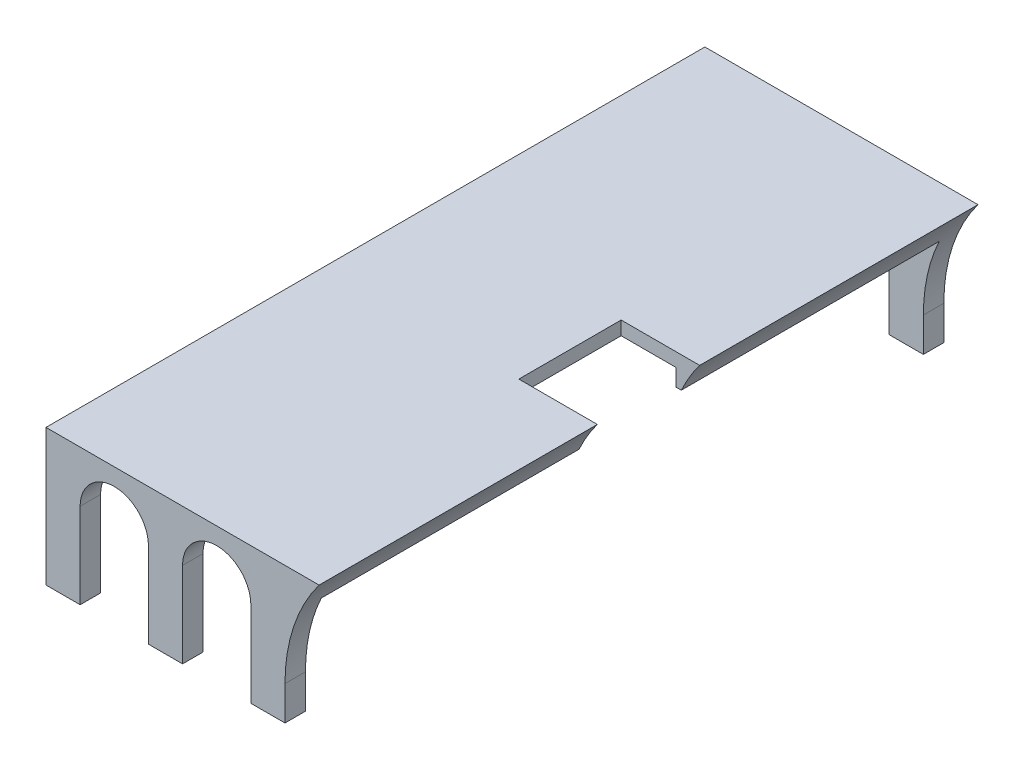
from build123d import *

# Parameters (mm, degrees)
SKETCH8_W           = 40
SKETCH8_H           = 20
BOSS_EXTRUDE1_DEPTH = 48.25
SKETCH10_W          = 36.5
SKETCH10_H          = 90.5
CUT_EXTRUDE6_DEPTH  = 18
SKETCH12_W          = 90.5
SKETCH12_H          = 15.5
CUT_EXTRUDE9_DEPTH  = 28
CUT_EXTRUDE10_DEPTH = 97.5
SKETCH14_W          = 13
SKETCH14_H          = 14.985683259
CUT_EXTRUDE11_DEPTH = 10
FILLET6_R           = 2.5
CUT_EXTRUDE12_DEPTH = 97.5


with BuildPart() as part:
    # Sketch8 → Boss-Extrude1 (new body, symmetric)
    with BuildSketch(Plane.XY):
        with Locations((0.738550377, -25.566858374)):
            Rectangle(SKETCH8_W, SKETCH8_H)
    extrude(amount=BOSS_EXTRUDE1_DEPTH, both=True)

    # Sketch10 → Cut-Extrude6 (cut)
    with BuildSketch(Plane(origin=(0, -35.566858374, 0), x_dir=(1, 0, 0), z_dir=(0, 1, 0))):
        with Locations((-1.011449623, 0)):
            Rectangle(SKETCH10_W, SKETCH10_H)
    extrude(amount=CUT_EXTRUDE6_DEPTH, mode=Mode.SUBTRACT)

    # Sketch12 → Cut-Extrude9 (cut)
    with BuildSketch(Plane(origin=(20.738550377, 0, 0), x_dir=(0, 0, -1), z_dir=(1, 0, 0))):
        with Locations((0, -27.816858374)):
            Rectangle(SKETCH12_W, SKETCH12_H)
    extrude(amount=-CUT_EXTRUDE9_DEPTH, mode=Mode.SUBTRACT)

    # Sketch13 → Cut-Extrude10 (cut, through all)
    with BuildSketch(Plane.XY.offset(48.25)):
        with BuildLine():
            Line((15.738550377, -35.566858374), (20.738550377, -35.566858374))
            Line((20.738550377, -35.566858374), (20.738550377, -15.566858374))
            ThreePointArc((20.738550377, -15.566858374), (17.021467925, -22.661164224), (15.738550377, -30.566858374))
            Line((15.738550377, -30.566858374), (15.738550377, -35.566858374))
        make_face()
    extrude(amount=-CUT_EXTRUDE10_DEPTH, mode=Mode.SUBTRACT)

    # Sketch14 → Cut-Extrude11 (cut)
    with BuildSketch(Plane.XZ.offset(15.566858374)):
        with Locations((15.738550377, 0.007158371)):
            Rectangle(SKETCH14_W, SKETCH14_H)
    extrude(amount=CUT_EXTRUDE11_DEPTH, mode=Mode.SUBTRACT)

    # Fillet6
    fillet6_edges = [part.edges().sort_by_distance(p)[0] for p in [
        (-1.011449623, -17.566858374, 45.25),
        (-1.011449623, -17.566858374, -45.25),
    ]]
    fillet(fillet6_edges, radius=FILLET6_R)

    # Sketch15 → Cut-Extrude12 (cut, through all)
    with BuildSketch(Plane.XY.offset(48.25)):
        with BuildLine():
            Line((-14.261449623, -35.566858374), (-4.261449623, -35.566858374))
            Line((-4.261449623, -35.566858374), (-4.261449623, -23.066858374))
            ThreePointArc((-4.261449623, -23.066858374), (-9.261449623, -18.066858374), (-14.261449623, -23.066858374))
            Line((-14.261449623, -23.066858374), (-14.261449623, -35.566858374))
        make_face()
        with BuildLine():
            Line((10.738550377, -35.566858374), (0.738550377, -35.566858374))
            Line((0.738550377, -35.566858374), (0.738550377, -23.066858374))
            ThreePointArc((0.738550377, -23.066858374), (5.738550377, -18.066858374), (10.738550377, -23.066858374))
            Line((10.738550377, -23.066858374), (10.738550377, -35.566858374))
        make_face()
    extrude(amount=-CUT_EXTRUDE12_DEPTH, mode=Mode.SUBTRACT)


solid = part.part
